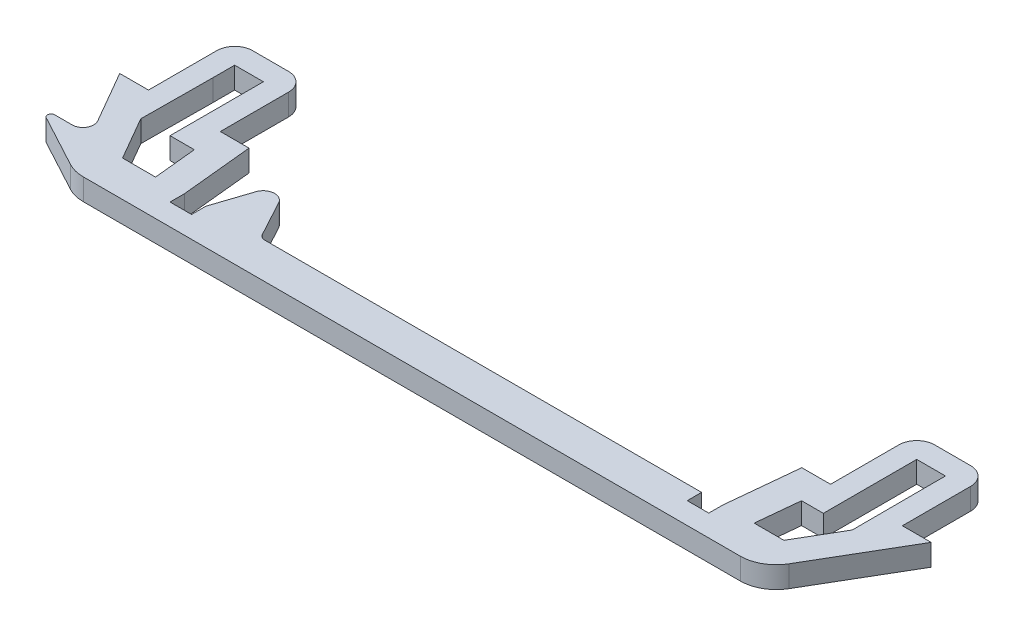
from build123d import *

# Parameters (mm, degrees)
BOSS_EXTRUDE1_DEPTH = 3
FILLET1_R           = 5
FILLET2_R           = 2.5
FILLET3_R           = 1


with BuildPart() as part:
    # Sketch1 → Boss-Extrude1 (new body)
    with BuildSketch(Plane(origin=(0, 0, 0), x_dir=(1, 0, 0), z_dir=(0, 1, 0))):
        with BuildLine():
            Line((-62.418566214, -50.1586621), (-58.418566214, -50.1586621))
            Line((-58.418566214, -50.1586621), (-58.418566214, -38.1586621))
            Line((-58.418566214, -38.1586621), (-48.418566214, -38.1586621))
            Line((-48.418566214, -38.1586621), (-48.418566214, -50.1586621))
            Line((-48.418566214, -50.1586621), (-44.418566214, -50.1586621))
            Line((-44.418566214, -50.1586621), (-43.418817081, -60.156153425))
            Line((-43.418817081, -60.156153425), (-43.418817081, -62.1586621))
            Line((-43.418817081, -62.1586621), (-40.418817081, -62.1586621))
            Line((-40.418817081, -62.1586621), (-40.418817081, -60.1586621))
            Line((-40.418817081, -60.1586621), (-38.682853905, -54.924562388))
            ThreePointArc((-38.682853905, -54.924562388), (-37.311808452, -53.840242209), (-35.772499384, -54.668519625))
            Line((-35.772499384, -54.668519625), (-32.803457275, -60.1586621))
            Line((-32.803457275, -60.1586621), (28.581433786, -60.1586621))
            Line((28.581433786, -60.1586621), (28.581433786, -62.1586621))
            Line((28.581433786, -62.1586621), (31.581433786, -62.1586621))
            Line((31.581433786, -62.1586621), (31.581433786, -60.208800497))
            Line((31.581433786, -60.208800497), (32.581433786, -50.211334262))
            Line((32.581433786, -50.211334262), (36.581433786, -50.211334262))
            Line((36.581433786, -50.211334262), (36.581433786, -38.211334262))
            Line((36.581433786, -38.211334262), (46.581433786, -38.211334262))
            Line((46.581433786, -38.211334262), (46.581433786, -50.211334262))
            Line((46.581433786, -50.211334262), (50.581433786, -50.211334262))
            Line((50.581433786, -50.211334262), (41.830582941, -65.1586621))
            Line((41.830582941, -65.1586621), (-53.758312176, -65.1586621))
            Line((-53.758312176, -65.1586621), (-62.202371167, -60.610709304))
            ThreePointArc((-62.202371167, -60.610709304), (-62.450096964, -60.048239346), (-61.965274707, -59.670498822))
            Line((-61.965274707, -59.670498822), (-59.524980934, -59.670498822))
            ThreePointArc((-59.524980934, -59.670498822), (-58.225942828, -58.920498822), (-58.225942828, -57.420498822))
            Line((-58.225942828, -57.420498822), (-62.418566214, -50.1586621))
        make_face()
        Polygon((36.547763078, -54.211334262), (39.581433786, -54.211334262), (39.581433786, -44.211334262), (39.581433786, -41.211334262), (43.581433786, -41.211334262), (43.581433786, -44.211334262), (43.604572315, -54.211334262), (40.093380681, -60.208800497), (35.947864455, -60.208800497), align=None, mode=Mode.SUBTRACT)
        Polygon((-55.418566214, -41.1586621), (-51.418566214, -41.1586621), (-51.418566214, -44.1586621), (-51.418566214, -54.1586621), (-48.038516462, -54.1586621), (-47.438516462, -60.1586621), (-52.026261368, -60.1586621), (-55.490362984, -54.1586621), (-55.418566214, -44.1586621), align=None, mode=Mode.SUBTRACT)
    extrude(amount=BOSS_EXTRUDE1_DEPTH)

    # Fillet1
    fillet1_edges = [part.edges().sort_by_distance(p)[0] for p in [
        (41.830582941, 1.5, 65.1586621),
        (-53.758312176, 1.5, 65.1586621),
    ]]
    fillet(fillet1_edges, radius=FILLET1_R)

    # Fillet2
    fillet2_edges = [part.edges().sort_by_distance(p)[0] for p in [
        (-58.418566214, 1.5, 38.1586621),
        (-48.418566214, 1.5, 38.1586621),
        (36.581433786, 1.5, 38.211334262),
        (46.581433786, 1.5, 38.211334262),
    ]]
    fillet(fillet2_edges, radius=FILLET2_R)

    # Fillet3
    fillet3_edges = [part.edges().sort_by_distance(p)[0] for p in [
        (-32.803457275, 1.5, 60.1586621),
    ]]
    fillet(fillet3_edges, radius=FILLET3_R)


solid = part.part
